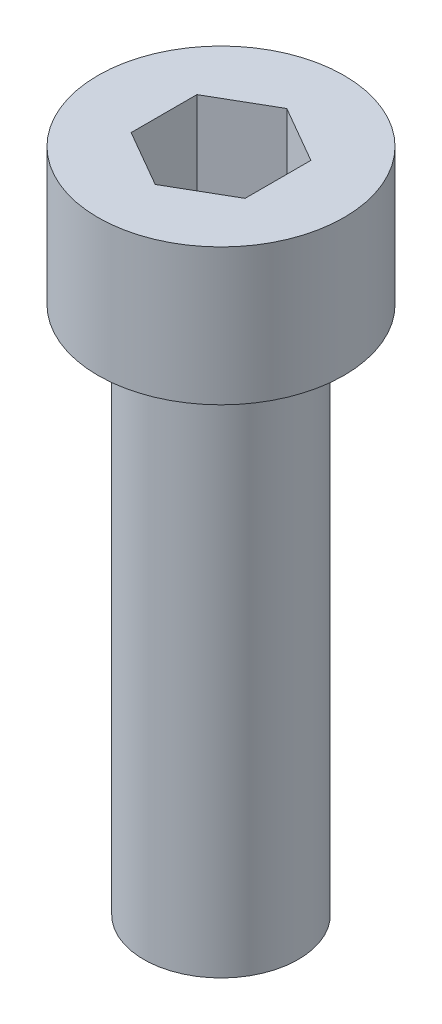
from build123d import *

# Parameters (mm, degrees)
SKETCH1_R           = 2.7
BOSS_EXTRUDE1_DEPTH = 3
SKETCH2_R           = 1.696293742
BOSS_EXTRUDE2_DEPTH = 11.6
CUT_EXTRUDE1_DEPTH  = 2


with BuildPart() as part:
    # Sketch1 → Boss-Extrude1 (new body)
    with BuildSketch(Plane(origin=(0, 0, 0), x_dir=(1, 0, 0), z_dir=(0, 1, 0))):
        with Locations((184.714490272, -125.24429514)):
            Circle(SKETCH1_R)
    extrude(amount=-BOSS_EXTRUDE1_DEPTH)

    # Sketch2 → Boss-Extrude2 (add)
    with BuildSketch(Plane.XZ.offset(3)):
        with Locations((184.714490272, 125.24429514)):
            Circle(SKETCH2_R)
    extrude(amount=BOSS_EXTRUDE2_DEPTH)

    # Sketch3 → Cut-Extrude1 (cut)
    with BuildSketch(Plane(origin=(0, 0, 0), x_dir=(1, 0, 0), z_dir=(0, 1, 0))):
        Polygon((184.714490272, -123.800919467), (183.464490272, -124.522607304), (183.464490272, -125.965982977), (184.714490272, -126.687670813), (185.964490272, -125.965982977), (185.964490272, -124.522607304), align=None)
    extrude(amount=-CUT_EXTRUDE1_DEPTH, mode=Mode.SUBTRACT)


solid = part.part
